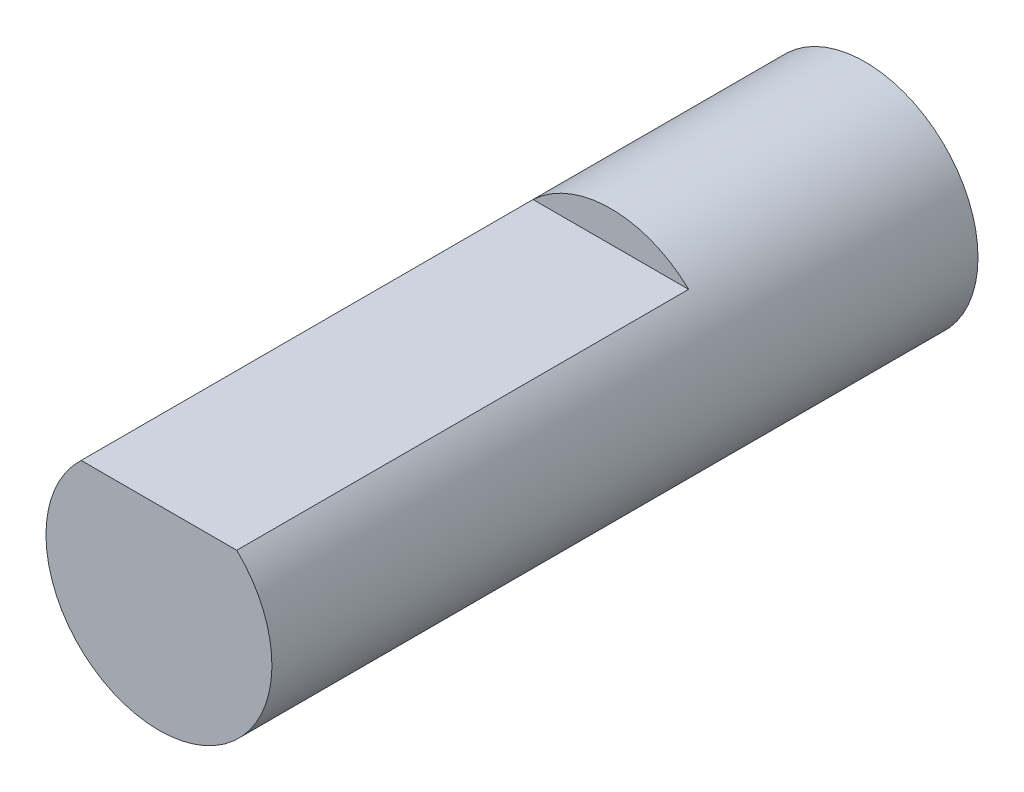
from build123d import *

# Parameters (mm, degrees)
SKETCH1_R           = 2
BOSS_EXTRUDE1_DEPTH = 12.5
CUT_EXTRUDE1_DEPTH  = 8


with BuildPart() as part:
    # Sketch1 → Boss-Extrude1 (new body)
    with BuildSketch(Plane.XY):
        Circle(SKETCH1_R)
    extrude(amount=BOSS_EXTRUDE1_DEPTH)

    # Sketch2 → Cut-Extrude1 (cut)
    with BuildSketch(Plane.XY.offset(12.5)):
        with BuildLine():
            Line((-1.377497731, 1.45), (1.377497731, 1.45))
            ThreePointArc((1.377497731, 1.45), (0, 2), (-1.377497731, 1.45))
        make_face()
    extrude(amount=-CUT_EXTRUDE1_DEPTH, mode=Mode.SUBTRACT)


solid = part.part
